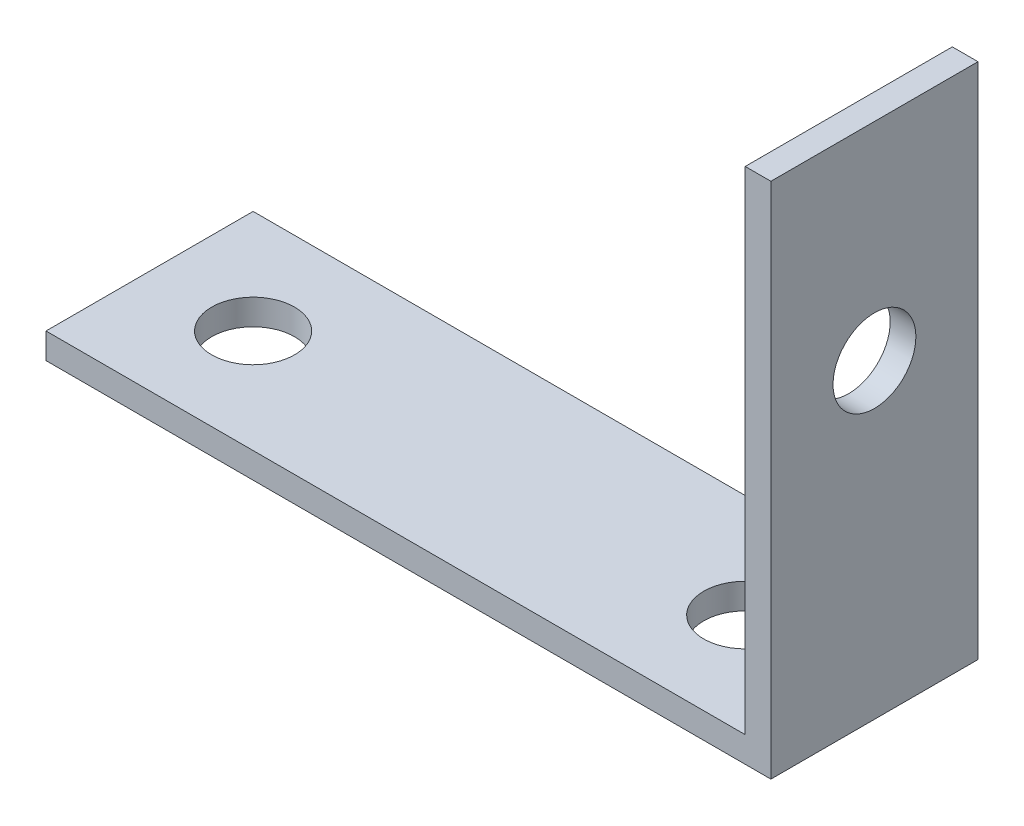
from build123d import *

# Parameters (mm, degrees)
BOSS_EXTRUDE1_DEPTH = 12.7
SKETCH2_R           = 2.54
CUT_EXTRUDE1_DEPTH  = 2.5748
SKETCH3_R           = 2.54
CUT_EXTRUDE2_DEPTH  = 2.5748


with BuildPart() as part:
    # Sketch1 → Boss-Extrude1 (new body)
    with BuildSketch(Plane.XY):
        Polygon((0, 0), (44.45, 0), (44.45, 31.75), (42.8752, 31.75), (42.8752, 1.5748), (0, 1.5748), align=None)
    extrude(amount=BOSS_EXTRUDE1_DEPTH)

    # Sketch2 → Cut-Extrude1 (cut, through all)
    with BuildSketch(Plane.ZY.offset(-42.8752)):
        with Locations((6.35, 19.05)):
            Circle(SKETCH2_R)
    extrude(amount=-CUT_EXTRUDE1_DEPTH, mode=Mode.SUBTRACT)

    # Sketch3 → Cut-Extrude2 (cut, through all)
    with BuildSketch(Plane(origin=(0, 1.5748, 0), x_dir=(1, 0, 0), z_dir=(0, 1, 0))):
        with Locations((6.35, -6.35)):
            Circle(SKETCH3_R)
        with Locations((36.5252, -6.35)):
            Circle(SKETCH3_R)
    extrude(amount=-CUT_EXTRUDE2_DEPTH, mode=Mode.SUBTRACT)


solid = part.part
